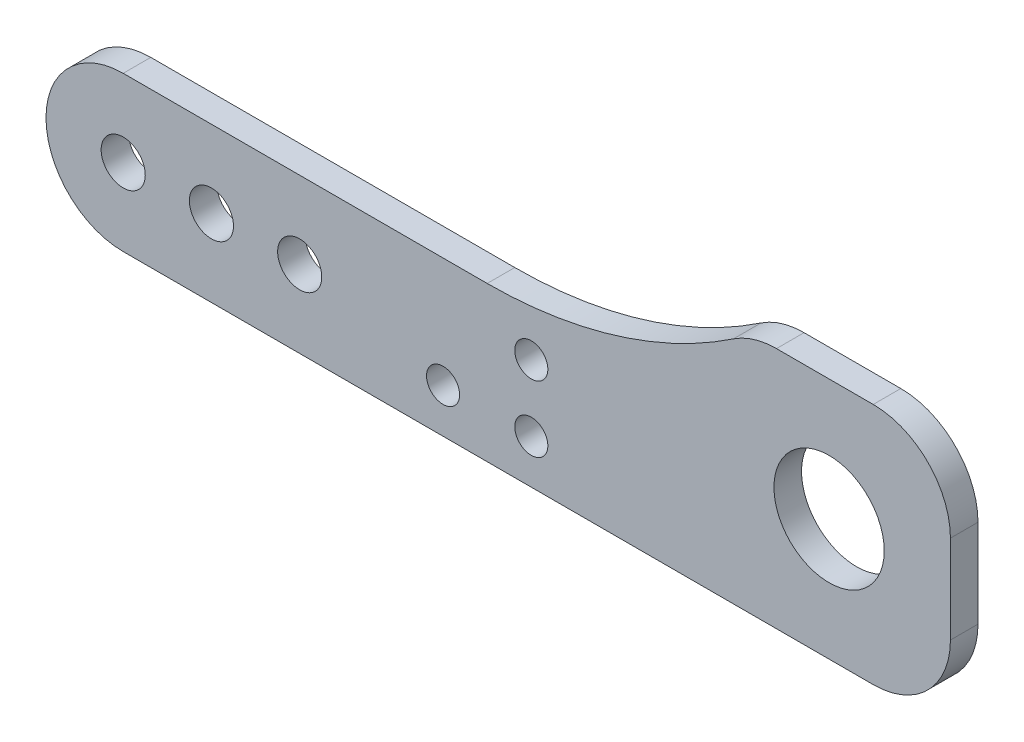
from build123d import *

# Parameters (mm, degrees)
BOSS_EXTRUDE1_DEPTH   = 2.5
SKETCH2_R             = 2
CUT_EXTRUDE1_DEPTH    = 2.5
SKETCH3_R             = 5
CUT_EXTRUDE2_DEPTH    = 2.5
F_3_0MM_DOWEL_HOLE2_D = 3


with BuildPart() as part:
    # Sketch1 → Boss-Extrude1 (new body)
    with BuildSketch(Plane.XY):
        with BuildLine():
            Line((0, 7), (33, 7))
            ThreePointArc((33, 7), (44.66919932, 8.739971416), (55.323194976, 13.808510638))
            ThreePointArc((55.323194976, 13.808510638), (57.187644216, 14.695505002), (59.229754097, 15))
            Line((59.229754097, 15), (68, 15))
            ThreePointArc((68, 15), (72.949747468, 12.949747468), (75, 8))
            Line((75, 8), (75, 0))
            ThreePointArc((75, 0), (72.949747468, -4.949747468), (68, -7))
            Line((68, -7), (0, -7))
            ThreePointArc((0, -7), (-7, 0), (0, 7))
        make_face()
    extrude(amount=BOSS_EXTRUDE1_DEPTH)

    # Sketch2 → Cut-Extrude1 (cut)
    with BuildSketch(Plane.XY.offset(2.5)):
        Circle(SKETCH2_R)
        with Locations((8, 0)):
            Circle(SKETCH2_R)
        with Locations((16, 0)):
            Circle(SKETCH2_R)
    extrude(amount=-CUT_EXTRUDE1_DEPTH, mode=Mode.SUBTRACT)

    # Sketch3 → Cut-Extrude2 (cut)
    with BuildSketch(Plane.XY.offset(2.5)):
        with Locations((64, 4)):
            Circle(SKETCH3_R)
    extrude(amount=-CUT_EXTRUDE2_DEPTH, mode=Mode.SUBTRACT)

    # Ø3.0mm Dowel Hole2 (through all)
    with Locations(Plane(origin=(0, 0, 0), x_dir=(-1, 0, 0), z_dir=(0, 0, -1))):
        with Locations((-37, 3), (-37, -3), (-29, -3)):
            Hole(F_3_0MM_DOWEL_HOLE2_D / 2)


solid = part.part
